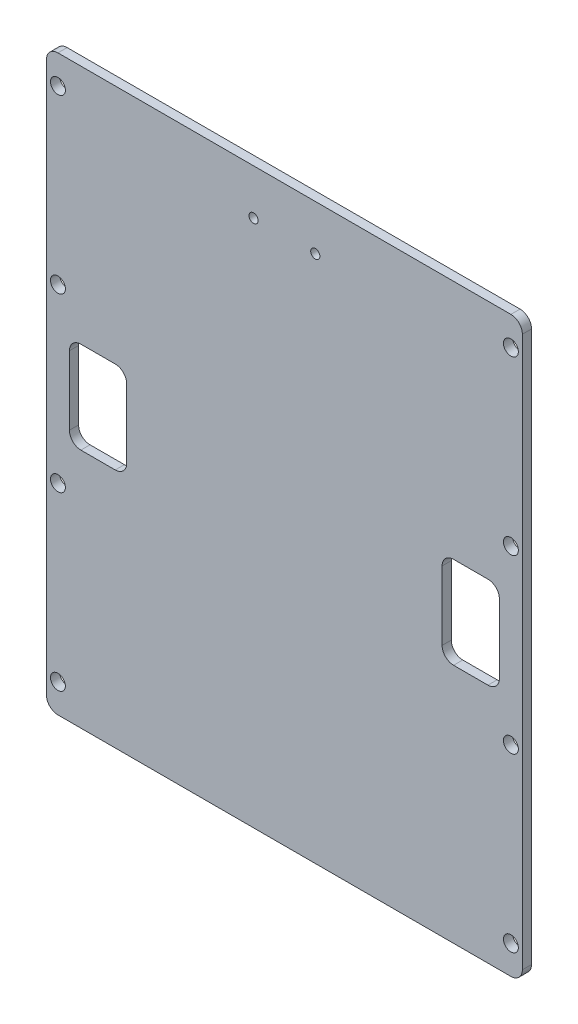
from build123d import *

# Parameters (mm, degrees)
BOARDOUTLINE_DEPTH   = 1.6
SKETCH2_R            = 0.8
COMPONENTHOLES_DEPTH = 2.6
WINDOWS_1SIDE_DEPTH  = 2.6
M2_CLEARANCE_HOLE1_D = 2.6


with BuildPart() as part:
    # Sketch1 → boardOutline (new body)
    with BuildSketch(Plane.XY):
        with BuildLine():
            Line((-39.5, -50), (39.5, -50))
            ThreePointArc((39.5, -50), (40.914213562, -49.414213562), (41.5, -48))
            Line((41.5, -48), (41.5, 48))
            ThreePointArc((41.5, 48), (40.914213562, 49.414213562), (39.5, 50))
            Line((39.5, 50), (-39.5, 50))
            ThreePointArc((-39.5, 50), (-40.914213562, 49.414213562), (-41.5, 48))
            Line((-41.5, 48), (-41.5, -48))
            ThreePointArc((-41.5, -48), (-40.914213562, -49.414213562), (-39.5, -50))
        make_face()
    extrude(amount=BOARDOUTLINE_DEPTH)

    # Sketch2 → componentHoles (cut, through all)
    with BuildSketch(Plane.XY.offset(1.6)):
        with Locations((-5.385, 42.1)):
            Circle(SKETCH2_R)
        with Locations((5.385, 42.1)):
            Circle(SKETCH2_R)
    extrude(amount=-COMPONENTHOLES_DEPTH, mode=Mode.SUBTRACT)

    # Sketch3 → windows_1side (cut, through all)
    with BuildSketch(Plane.XY.offset(1.6)):
        with BuildLine():
            Line((37.5, -6), (37.5, 6))
            ThreePointArc((37.5, 6), (36.914213562, 7.414213562), (35.5, 8))
            Line((35.5, 8), (29.5, 8))
            ThreePointArc((29.5, 8), (28.085786438, 7.414213562), (27.5, 6))
            Line((27.5, 6), (27.5, -6))
            ThreePointArc((27.5, -6), (28.085786438, -7.414213562), (29.5, -8))
            Line((29.5, -8), (35.5, -8))
            ThreePointArc((35.5, -8), (36.914213562, -7.414213562), (37.5, -6))
        make_face()
        with BuildLine():
            Line((-29.5, -8), (-35.5, -8))
            ThreePointArc((-35.5, -8), (-36.914213562, -7.414213562), (-37.5, -6))
            Line((-37.5, -6), (-37.5, 6))
            ThreePointArc((-37.5, 6), (-36.914213562, 7.414213562), (-35.5, 8))
            Line((-35.5, 8), (-29.5, 8))
            ThreePointArc((-29.5, 8), (-28.085786438, 7.414213562), (-27.5, 6))
            Line((-27.5, 6), (-27.5, -6))
            ThreePointArc((-27.5, -6), (-28.085786438, -7.414213562), (-29.5, -8))
        make_face()
    extrude(amount=-WINDOWS_1SIDE_DEPTH, mode=Mode.SUBTRACT)

    # M2 Clearance Hole1 (through all)
    with Locations(Plane(origin=(0, 0, 0), x_dir=(-1, 0, 0), z_dir=(0, 0, -1))):
        with Locations((39.5, 45), (39.5, -15), (39.5, -45), (39.5, 15)):
            m2_clearance_hole1 = Hole(M2_CLEARANCE_HOLE1_D / 2)

    # Mirror1: M2 Clearance Hole1 across plane
    add(m2_clearance_hole1.mirror(Plane(origin=(0, 0, 0), x_dir=(0, 0, 1), z_dir=(1, 0, 0))), mode=Mode.SUBTRACT)


solid = part.part
